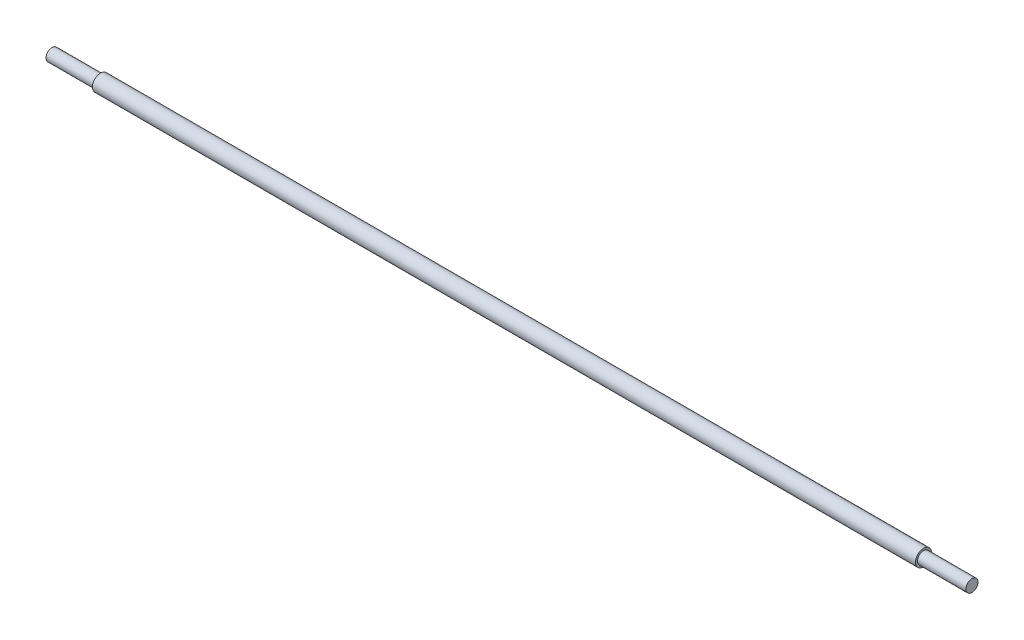
from build123d import *


with BuildPart() as part:
    # Sketch2 → Revolve1 (revolve)
    with BuildSketch(Plane(origin=(0, 0, 0), x_dir=(1, 0, 0), z_dir=(0, 1, 0))):
        Polygon((-723.9, 0), (723.9, 0), (723.9, 9.525), (647.7, 9.525), (647.7, 12.7), (-647.7, 12.7), (-647.7, 9.525), (-723.9, 9.525), align=None)
    revolve(axis=Axis((-723.9, 0, 0), (1, 0, 0)))


solid = part.part
